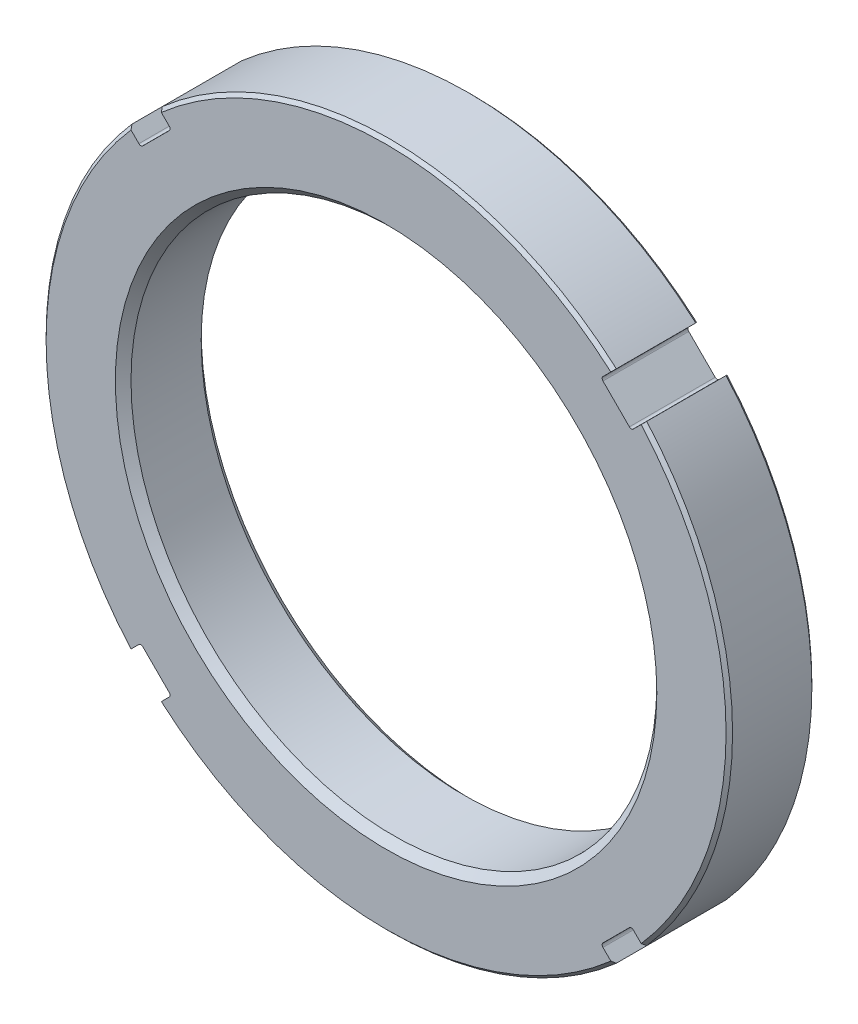
from build123d import *

# Parameters (mm, degrees)
SKETCH1_R                = 50.8
SKETCH1_R_2              = 38.9128
EXTRUDE1_DEPTH           = 12.7
CHAMFER1_SIZE            = 0.480314
CHAMFER2_SIZE            = 1.1557
CUT_EXTRUDE1_DEPTH       = 13.7
FILLET1_R                = 0.4064
CIRPATTERN1_COUNT        = 4
FILLET1_OF_CIRPATTERN1_R = 0.4064


with BuildPart() as part:
    # Sketch1 → Extrude1 (new body)
    with BuildSketch(Plane.XY):
        Circle(SKETCH1_R)
        Circle(SKETCH1_R_2, mode=Mode.SUBTRACT)
    extrude(amount=EXTRUDE1_DEPTH)

    # Chamfer1
    chamfer1_edges = [part.edges().sort_by_distance(p)[0] for p in [
        (-50.8, 0, 0),
        (-50.8, 0, 12.7),
    ]]
    chamfer(chamfer1_edges, length=CHAMFER1_SIZE)

    # Chamfer2
    chamfer2_edges = [part.edges().sort_by_distance(p)[0] for p in [
        (-38.9128, 0, 0),
        (-38.9128, 0, 12.7),
    ]]
    chamfer(chamfer2_edges, length=CHAMFER2_SIZE)

    # Sketch2 → Cut-Extrude1 (cut, through all)
    with BuildSketch(Plane.XY.offset(12.7)):
        with BuildLine():
            Line((33.605733555, 38.095861616), (31.808067181, 36.298195241))
            Line((31.808067181, 36.298195241), (36.298195241, 31.808067181))
            Line((36.298195241, 31.808067181), (38.095861616, 33.605733555))
            ThreePointArc((38.095861616, 33.605733555), (35.921024484, 35.921024484), (33.605733555, 38.095861616))
        make_face()
    cut_extrude1 = extrude(amount=-CUT_EXTRUDE1_DEPTH, mode=Mode.SUBTRACT)

    # Fillet1
    fillet1_edges = [part.edges().sort_by_distance(p)[0] for p in [
        (36.298195241, 31.808067181, 6.35),
        (31.808067181, 36.298195241, 6.35),
    ]]
    fillet(fillet1_edges, radius=FILLET1_R)

    # CirPattern1: Cut-Extrude1 ×4 about axis
    cirpattern1_axis = Axis((0, 0, 0), (0, 0, 1))
    for i in range(1, CIRPATTERN1_COUNT):
        add(cut_extrude1.rotate(cirpattern1_axis, i * 360 / CIRPATTERN1_COUNT), mode=Mode.SUBTRACT)

    # Fillet1 of CirPattern1
    fillet1_of_cirpattern1_edges = [part.edges().sort_by_distance(p)[0] for p in [
        (-31.808067181, 36.298195241, 6.35),
        (-36.298195241, 31.808067181, 6.35),
        (-36.298195241, -31.808067181, 6.35),
        (-31.808067181, -36.298195241, 6.35),
        (31.808067181, -36.298195241, 6.35),
        (36.298195241, -31.808067181, 6.35),
    ]]
    fillet(fillet1_of_cirpattern1_edges, radius=FILLET1_OF_CIRPATTERN1_R)


solid = part.part
